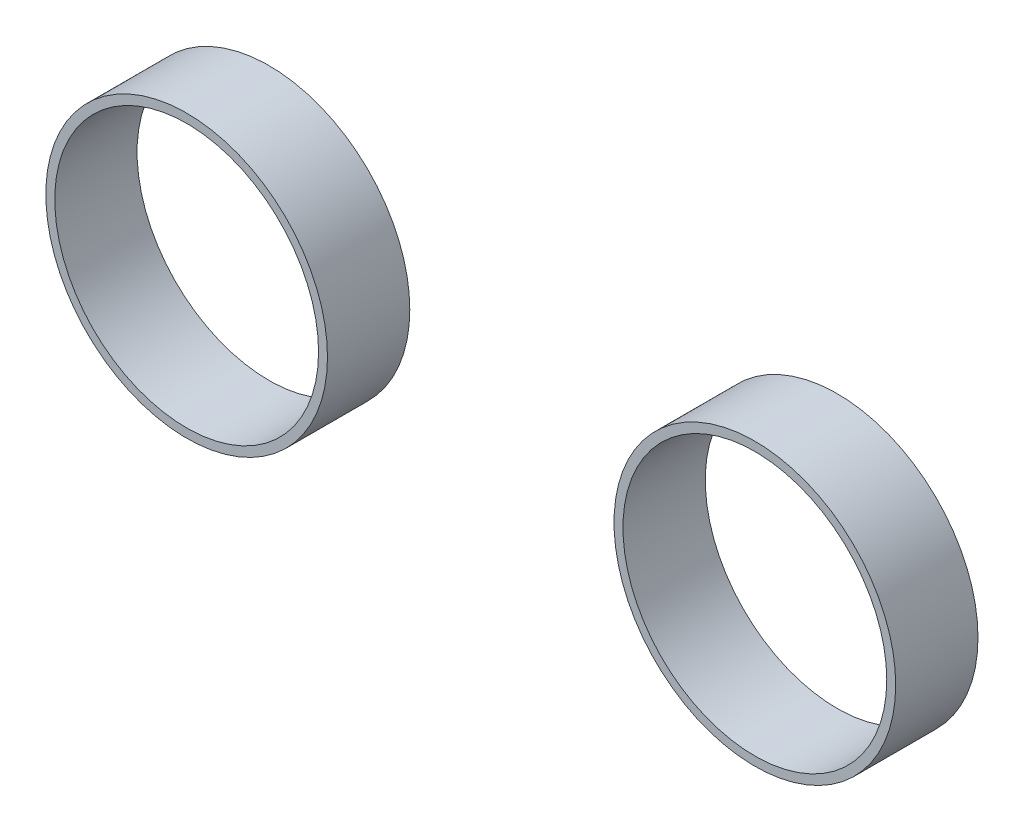
from build123d import *

# Parameters (mm, degrees)
SKETCH1_R             = 69.4
SKETCH1_R_2           = 65
BOSS_EXTRUDE1_DEPTH   = 40.56
BOSS_EXTRUDE1_2_DEPTH = 40.56


with BuildPart() as part:
    # Sketch1 → Boss-Extrude1 (new body)
    with BuildSketch(Plane.XY):
        with Locations((1715.980472759, -423.382336202)):
            Circle(SKETCH1_R)
        with Locations((1715.980472759, -423.382336202)):
            Circle(SKETCH1_R_2, mode=Mode.SUBTRACT)
    extrude(amount=-BOSS_EXTRUDE1_DEPTH)


with BuildPart() as body_2:
    # Sketch1 → Boss-Extrude1 2 (new body)
    with BuildSketch(Plane.XY):
        with Locations((1435.980472759, -423.382336202)):
            Circle(SKETCH1_R)
        with Locations((1435.980472759, -423.382336202)):
            Circle(SKETCH1_R_2, mode=Mode.SUBTRACT)
    extrude(amount=-BOSS_EXTRUDE1_2_DEPTH)


solid = Compound([part.part, body_2.part])
